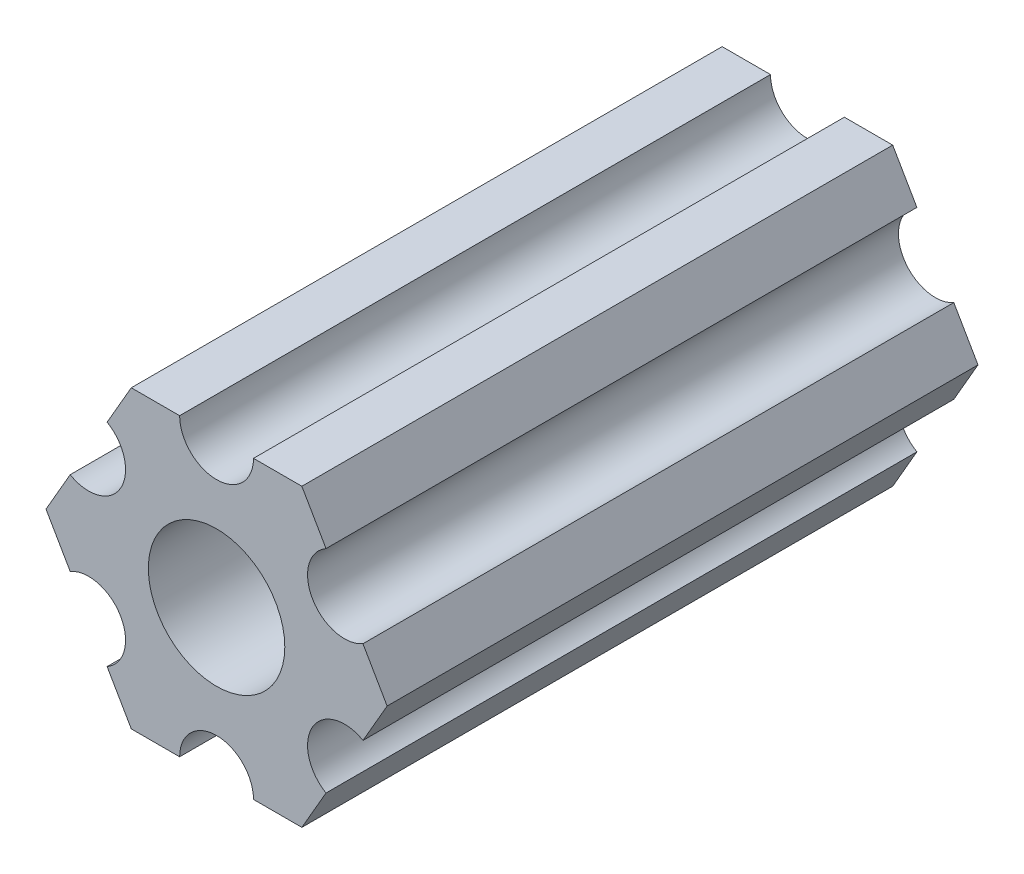
from build123d import *

# Parameters (mm, degrees)
SKETCH1_R           = 2.9337
BOSS_EXTRUDE1_DEPTH = 12.7


with BuildPart() as part:
    # Sketch1 → Boss-Extrude1 (new body, symmetric)
    with BuildSketch(Plane(origin=(0, 0, 0), x_dir=(-1, 0, 0), z_dir=(0, 0, -1))):
        with BuildLine():
            Line((-4.70551159, -4.549815043), (-3.666174521, -6.349999904))
            Line((-3.666174521, -6.349999904), (-1.587500385, -6.349999904))
            ThreePointArc((-1.587500385, -6.349999904), (-3.85e-07, -4.762499904), (1.587499615, -6.349999904))
            Line((1.587499615, -6.349999904), (3.666173825, -6.349999904))
            Line((3.666173825, -6.349999904), (4.705510942, -4.54981524))
            ThreePointArc((4.705510942, -4.54981524), (4.124445629, -2.381249907), (6.293010962, -1.800184594))
            Line((6.293010962, -1.800184594), (7.332348079, 7e-08))
            Line((7.332348079, 7e-08), (6.293011217, 1.800184685))
            ThreePointArc((6.293011217, 1.800184685), (4.124445939, 2.381250203), (4.705511457, 4.549815481))
            Line((4.705511457, 4.549815481), (3.666174521, 6.350000222))
            Line((3.666174521, 6.350000222), (1.587500385, 6.350000222))
            ThreePointArc((1.587500385, 6.350000222), (3.85e-07, 4.762500222), (-1.587499615, 6.350000222))
            Line((-1.587499615, 6.350000222), (-3.666173825, 6.350000222))
            Line((-3.666173825, 6.350000222), (-4.705511038, 4.549815614))
            ThreePointArc((-4.705511038, 4.549815614), (-4.124445841, 2.38125025), (-6.293011205, 1.800185053))
            Line((-6.293011205, 1.800185053), (-7.332348419, 4.44e-07))
            Line((-7.332348419, 4.44e-07), (-6.293011423, -1.80018429))
            ThreePointArc((-6.293011423, -1.80018429), (-4.12444613, -2.38124975), (-4.70551159, -4.549815043))
        make_face()
        Circle(SKETCH1_R, mode=Mode.SUBTRACT)
    extrude(amount=BOSS_EXTRUDE1_DEPTH, both=True)


solid = part.part
